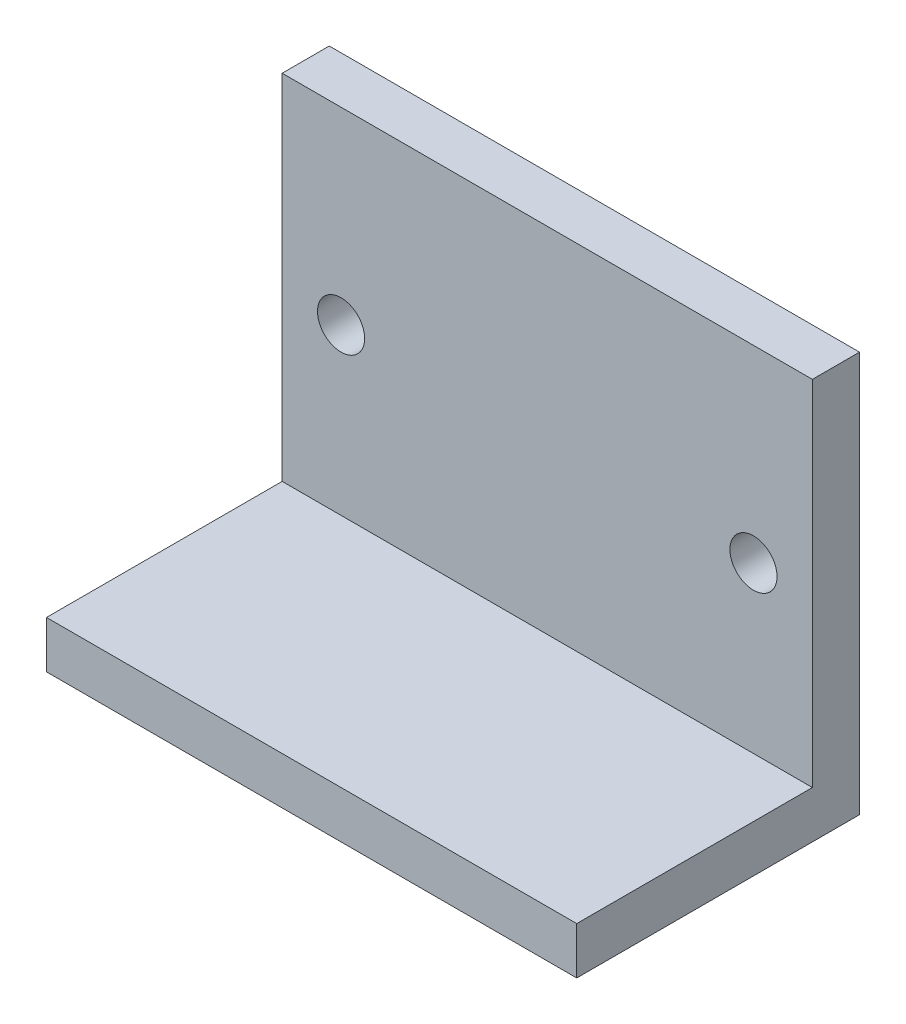
from build123d import *

# Parameters (mm, degrees)
SKETCH1_W           = 45
SKETCH1_H           = 34
BOSS_EXTRUDE1_DEPTH = 4
SKETCH2_W           = 45
SKETCH2_H           = 4
BOSS_EXTRUDE2_DEPTH = 20
SKETCH3_R           = 2
CUT_EXTRUDE1_DEPTH  = 10


with BuildPart() as part:
    # Sketch1 → Boss-Extrude1 (new body)
    with BuildSketch(Plane.XY):
        with Locations((22.5, 17)):
            Rectangle(SKETCH1_W, SKETCH1_H)
    extrude(amount=BOSS_EXTRUDE1_DEPTH)

    # Sketch2 → Boss-Extrude2 (add)
    with BuildSketch(Plane.XY.offset(4)):
        with Locations((22.5, 2)):
            Rectangle(SKETCH2_W, SKETCH2_H)
    extrude(amount=BOSS_EXTRUDE2_DEPTH)

    # Sketch3 → Cut-Extrude1 (cut)
    with BuildSketch(Plane.XY.offset(4)):
        with Locations((5, 18)):
            Circle(SKETCH3_R)
        with Locations((40, 18)):
            Circle(SKETCH3_R)
    extrude(amount=-CUT_EXTRUDE1_DEPTH, mode=Mode.SUBTRACT)


solid = part.part
